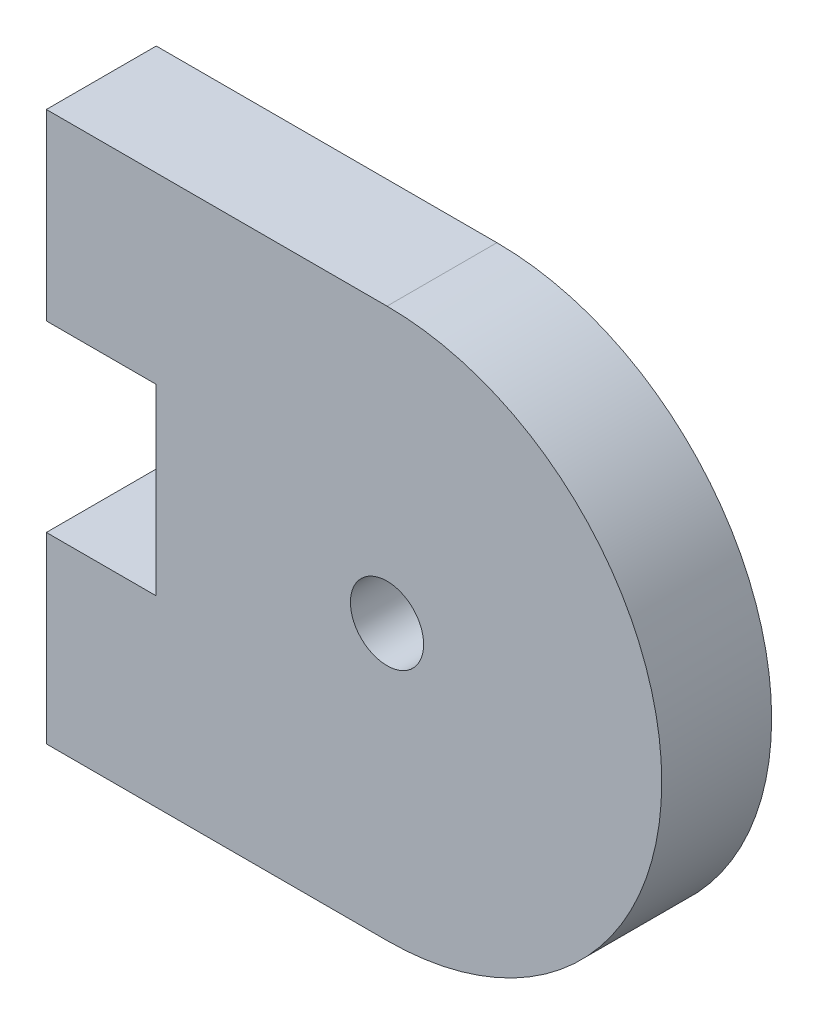
from build123d import *

# Parameters (mm, degrees)
MODEL_R                 = 1
SALIENTE_EXTRUIR1_DEPTH = 3
CROQUIS2_R              = 2.15
CORTAR_EXTRUIR1_DEPTH   = 1


with BuildPart() as part:
    # Model → Saliente-Extruir1 (new body)
    with BuildSketch(Plane.XY):
        with BuildLine():
            Line((26.66, 16.366878764), (26.66, 11.366878764))
            Line((26.66, 11.366878764), (35.96, 11.366878764))
            ThreePointArc((35.96, 11.366878764), (43.46, 18.866878764), (35.96, 26.366878764))
            Line((35.96, 26.366878764), (26.66, 26.366878764))
            Line((26.66, 26.366878764), (26.66, 21.366878764))
            Line((26.66, 21.366878764), (29.66, 21.366878764))
            Line((29.66, 21.366878764), (29.66, 16.366878764))
            Line((29.66, 16.366878764), (26.66, 16.366878764))
        make_face()
        with Locations((35.96, 18.866878764)):
            Circle(MODEL_R, mode=Mode.SUBTRACT)
    extrude(amount=SALIENTE_EXTRUIR1_DEPTH)

    # Croquis2 → Cortar-Extruir1 (cut)
    with BuildSketch(Plane.XY):
        with Locations((35.96, 18.866878764)):
            Circle(CROQUIS2_R)
    extrude(amount=CORTAR_EXTRUIR1_DEPTH, mode=Mode.SUBTRACT)


solid = part.part
